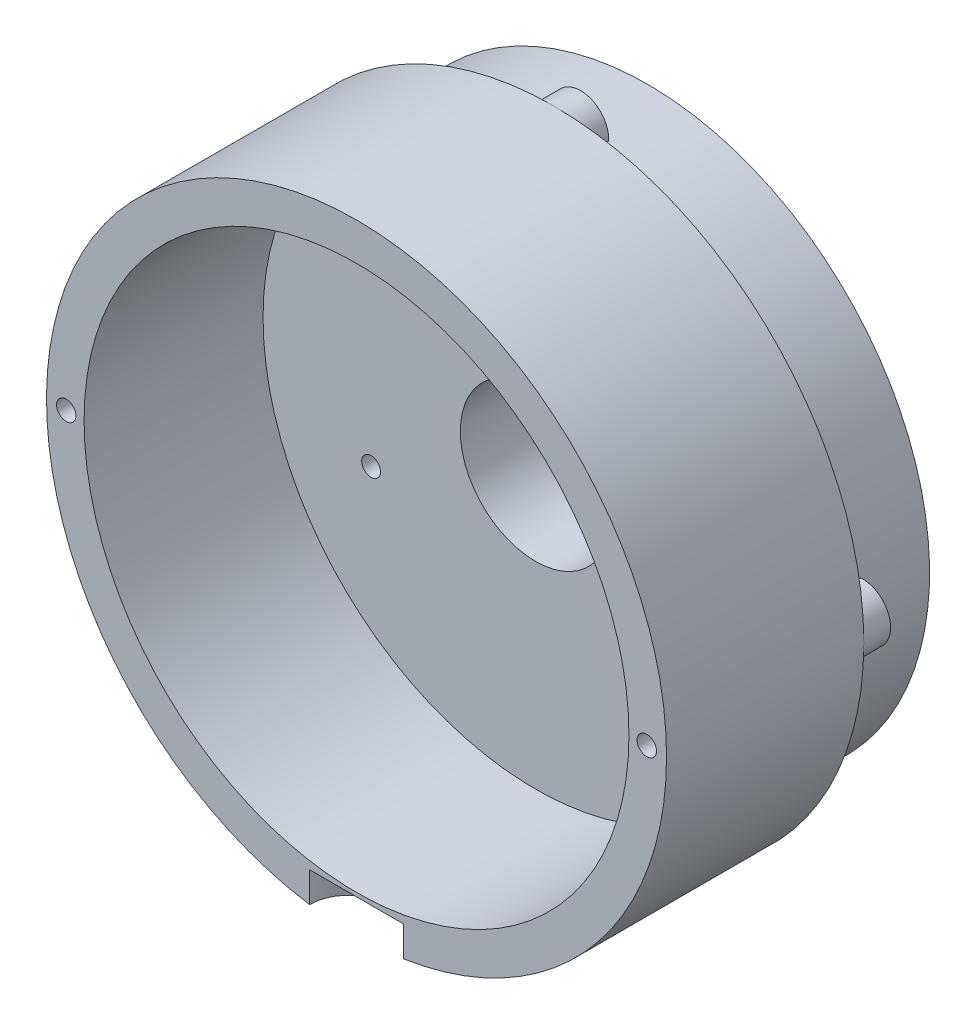
from build123d import *

# Parameters (mm, degrees)
SKETCH1_R           = 33
BOSS_EXTRUDE1_DEPTH = 21
SKETCH2_R           = 29
CUT_EXTRUDE1_DEPTH  = 19.05
SKETCH3_R           = 30
BOSS_EXTRUDE2_DEPTH = 10
BOSS_EXTRUDE3_DEPTH = 2.85
SKETCH5_R           = 8
SKETCH5_R_2         = 3
CUT_EXTRUDE2_DEPTH  = 32
SKETCH6_R           = 4.1
CUT_EXTRUDE3_DEPTH  = 3
SKETCH10_R          = 1.0325
CUT_EXTRUDE4_DEPTH  = 5
CUT_EXTRUDE5_DEPTH  = 3.6
SKETCH12_R          = 1
CUT_EXTRUDE6_DEPTH  = 3


with BuildPart() as part:
    # Sketch1 → Boss-Extrude1 (new body)
    with BuildSketch(Plane.XY):
        Circle(SKETCH1_R)
    extrude(amount=-BOSS_EXTRUDE1_DEPTH)

    # Sketch2 → Cut-Extrude1 (cut)
    with BuildSketch(Plane.XY):
        Circle(SKETCH2_R)
    extrude(amount=-CUT_EXTRUDE1_DEPTH, mode=Mode.SUBTRACT)

    # Sketch3 → Boss-Extrude2 (add)
    with BuildSketch(Plane(origin=(0, 0, -21), x_dir=(-1, 0, 0), z_dir=(0, 0, -1))):
        Circle(SKETCH3_R)
    extrude(amount=BOSS_EXTRUDE2_DEPTH)

    # Sketch4 → Boss-Extrude3 (add)
    with BuildSketch(Plane(origin=(0, 0, -21), x_dir=(-1, 0, 0), z_dir=(0, 0, -1))):
        with BuildLine():
            ThreePointArc((-29.85, 2.996247653), (-33, 0), (-29.85, -2.996247653))
            ThreePointArc((-29.85, -2.996247653), (-30, 0), (-29.85, 2.996247653))
        make_face()
        with BuildLine():
            ThreePointArc((2.996247653, 29.85), (0, 33), (-2.996247653, 29.85))
            ThreePointArc((-2.996247653, 29.85), (0, 30), (2.996247653, 29.85))
        make_face()
        with BuildLine():
            ThreePointArc((29.85, -2.996247653), (33, 0), (29.85, 2.996247653))
            ThreePointArc((29.85, 2.996247653), (30, 0), (29.85, -2.996247653))
        make_face()
        with BuildLine():
            ThreePointArc((-2.996247653, -29.85), (0, -33), (2.996247653, -29.85))
            ThreePointArc((2.996247653, -29.85), (0, -30), (-2.996247653, -29.85))
        make_face()
    extrude(amount=BOSS_EXTRUDE3_DEPTH)

    # Sketch5 → Cut-Extrude2 (cut, through all)
    with BuildSketch(Plane(origin=(0, 0, -31), x_dir=(-1, 0, 0), z_dir=(0, 0, -1))):
        Circle(SKETCH5_R)
        with Locations((0, 15)):
            Circle(SKETCH5_R_2)
    extrude(amount=-CUT_EXTRUDE2_DEPTH, mode=Mode.SUBTRACT)

    # Sketch6 → Cut-Extrude3 (cut)
    with BuildSketch(Plane.XY.offset(-19.05)):
        with Locations((0, 15)):
            Circle(SKETCH6_R)
    extrude(amount=-CUT_EXTRUDE3_DEPTH, mode=Mode.SUBTRACT)

    # Sketch9 → Cut-Revolve1 (revolve, cut)
    with BuildSketch(Plane(origin=(0, 0, 0), x_dir=(0, 0, -1), z_dir=(1, 0, 0))):
        Polygon((22.05, 18), (22.05, 18.8), (31, 18), align=None)
    revolve(axis=Axis((0, 15, -31), (0, 0, 1)), mode=Mode.SUBTRACT)

    # Sketch10 → Cut-Extrude4 (cut)
    with BuildSketch(Plane.XY):
        with Locations((-30.9, 0)):
            Circle(SKETCH10_R)
        with Locations((30.9, 0)):
            Circle(SKETCH10_R)
    extrude(amount=-CUT_EXTRUDE4_DEPTH, mode=Mode.SUBTRACT)

    # Sketch11 → Cut-Extrude5 (cut)
    with BuildSketch(Plane(origin=(0, -33, 0), x_dir=(-1, 0, 0), z_dir=(0, -1, 0))):
        with BuildLine():
            Line((-5, 0), (5, 0))
            ThreePointArc((5, 0), (0, 5), (-5, 0))
        make_face()
    extrude(amount=-CUT_EXTRUDE5_DEPTH, mode=Mode.SUBTRACT)

    # Sketch12 → Cut-Extrude6 (cut)
    with BuildSketch(Plane.XY.offset(-19.05)):
        with Locations((17.5, -8)):
            Circle(SKETCH12_R)
        with Locations((-17.5, -8)):
            Circle(SKETCH12_R)
    extrude(amount=-CUT_EXTRUDE6_DEPTH, mode=Mode.SUBTRACT)


solid = part.part
